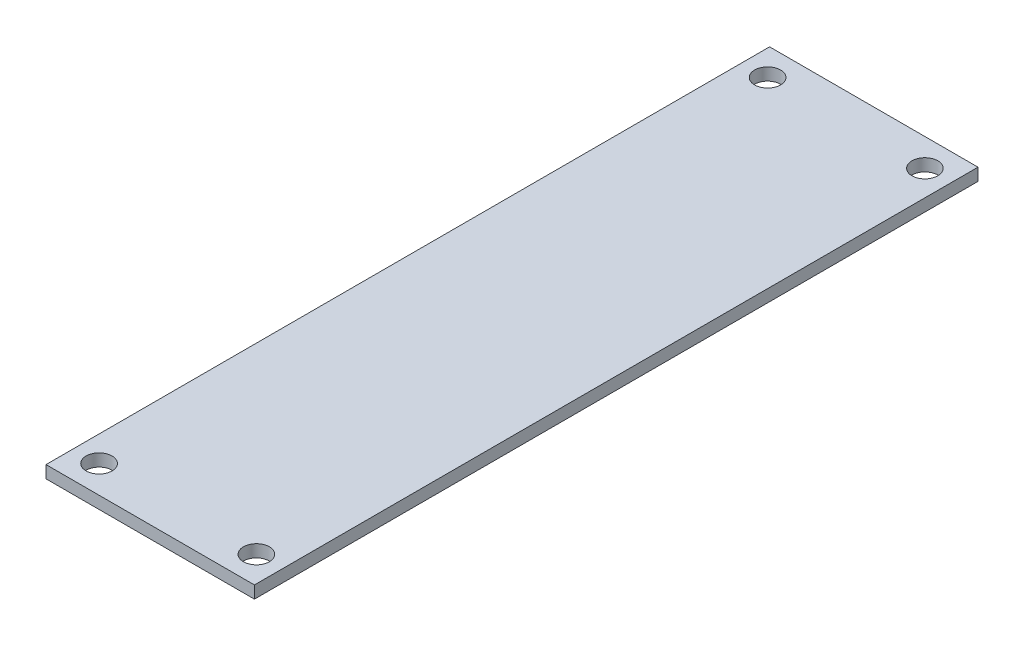
from build123d import *

# Parameters (mm, degrees)
SKETCH1_W           = 26.5
SKETCH1_H           = 92
SKETCH1_R           = 1.65
BOSS_EXTRUDE1_DEPTH = 1.57


with BuildPart() as part:
    # Sketch1 → Boss-Extrude1 (new body)
    with BuildSketch(Plane(origin=(0, 0, 0), x_dir=(1, 0, 0), z_dir=(0, 1, 0))):
        Rectangle(SKETCH1_W, SKETCH1_H)
        with Locations((-10, 42.5)):
            Circle(SKETCH1_R, mode=Mode.SUBTRACT)
        with Locations((10, 42.5)):
            Circle(SKETCH1_R, mode=Mode.SUBTRACT)
        with Locations((10, -42.5)):
            Circle(SKETCH1_R, mode=Mode.SUBTRACT)
        with Locations((-10, -42.5)):
            Circle(SKETCH1_R, mode=Mode.SUBTRACT)
    extrude(amount=BOSS_EXTRUDE1_DEPTH)


solid = part.part
